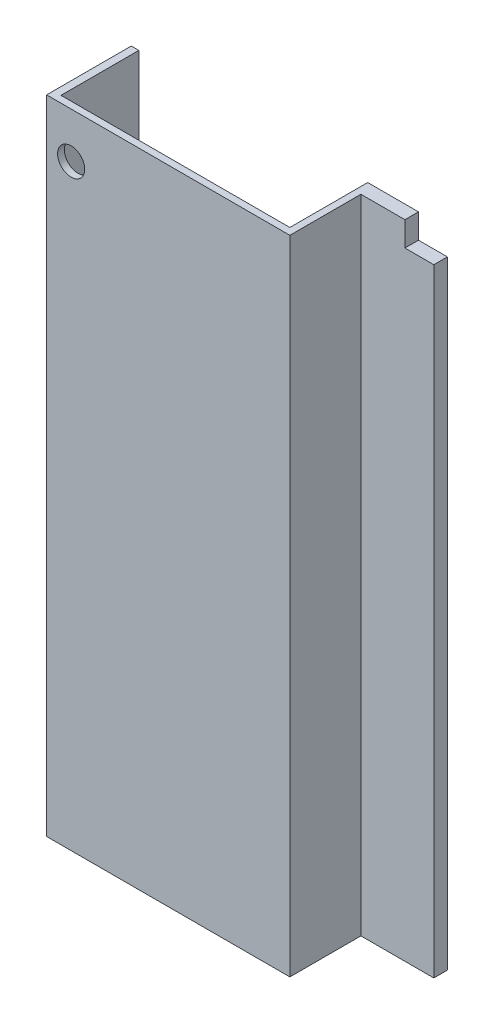
from build123d import *

# Parameters (mm, degrees)
BOSS_EXTRUDE1_DEPTH = 2405.888
SKETCH3_W           = 108.204
SKETCH3_H           = 91.948
CUT_EXTRUDE1_DEPTH  = 50.8
SKETCH4_R           = 50.8
CUT_EXTRUDE2_DEPTH  = 25.4


with BuildPart() as part:
    # Sketch2 → Boss-Extrude1 (new body)
    with BuildSketch(Plane(origin=(0, 0, 0), x_dir=(1, 0, 0), z_dir=(0, 1, 0))):
        Polygon((-457.073, 291.592), (-428.625, 291.592), (-428.625, 0), (428.625, 0), (428.625, 291.592), (727.075, 291.592), (727.075, 240.792), (454.025, 240.792), (454.025, -25.4), (-457.073, -25.4), align=None)
    extrude(amount=BOSS_EXTRUDE1_DEPTH)

    # Sketch3 → Cut-Extrude1 (cut)
    with BuildSketch(Plane.XY.offset(-240.792)):
        with Locations((672.973, 2359.914)):
            Rectangle(SKETCH3_W, SKETCH3_H)
    extrude(amount=-CUT_EXTRUDE1_DEPTH, mode=Mode.SUBTRACT)

    # Sketch4 → Cut-Extrude2 (cut)
    with BuildSketch(Plane.XY.offset(25.4)):
        with Locations((-365.125, 2235.708)):
            Circle(SKETCH4_R)
    extrude(amount=-CUT_EXTRUDE2_DEPTH, mode=Mode.SUBTRACT)


solid = part.part
